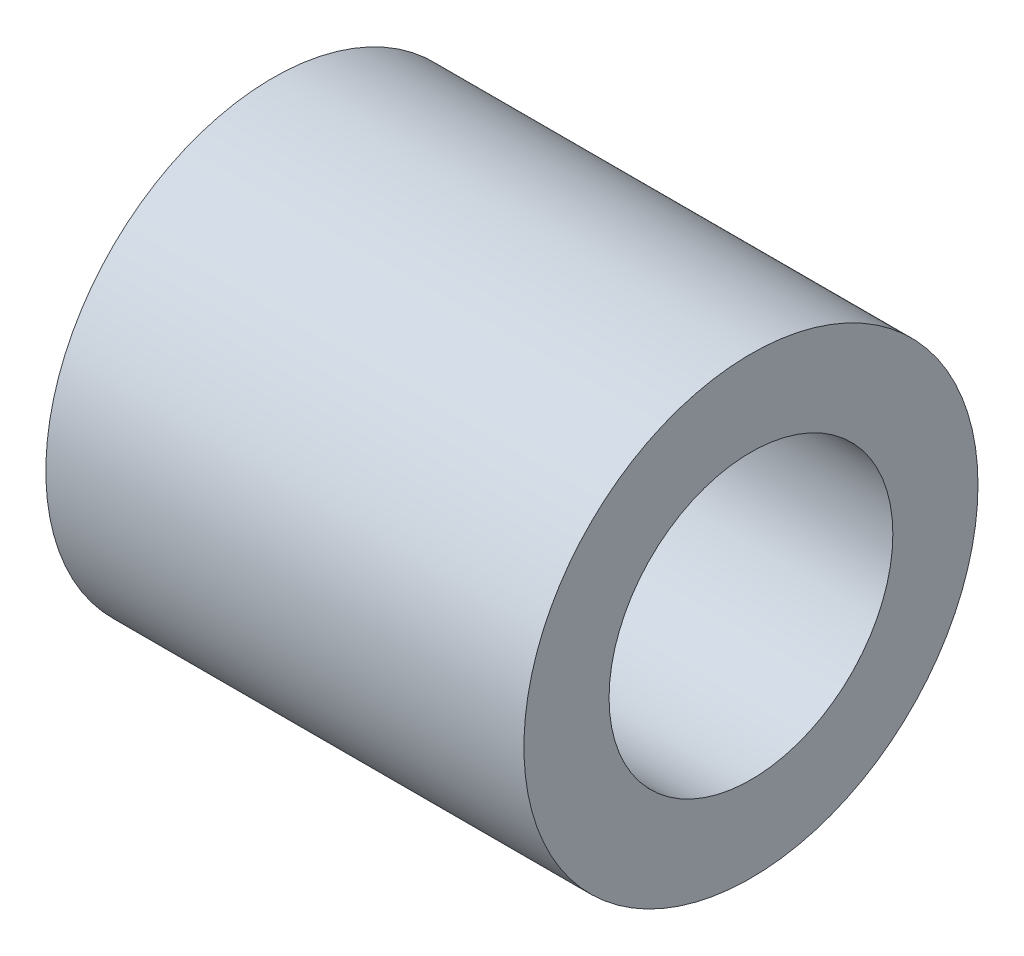
from build123d import *

# Parameters (mm, degrees)
SKETCH1_R           = 4
BOSS_EXTRUDE1_DEPTH = 9
CHAMFER1_SIZE       = 1
CHAMFER1_SIZE2      = 0.577350269
SKETCH2_R           = 2.5
CUT_EXTRUDE1_DEPTH  = 6


with BuildPart() as part:
    # Sketch1 → Boss-Extrude1 (new body)
    with BuildSketch(Plane(origin=(0, 0, 0), x_dir=(0, 0, -1), z_dir=(1, 0, 0))):
        Circle(SKETCH1_R)
    extrude(amount=BOSS_EXTRUDE1_DEPTH)

    # Chamfer1
    chamfer1_edges = [part.edges().sort_by_distance(p)[0] for p in [
        (0, 0, 4),
    ]]
    chamfer1_side = [part.faces().sort_by_distance(p)[0] for p in [
        (0, 0, 0),
    ]]
    chamfer(chamfer1_edges, length=CHAMFER1_SIZE, length2=CHAMFER1_SIZE2, reference=chamfer1_side[0])

    # Sketch2 → Cut-Extrude1 (cut)
    with BuildSketch(Plane(origin=(9, 0, 0), x_dir=(0, 0, -1), z_dir=(1, 0, 0))):
        Circle(SKETCH2_R)
    extrude(amount=-CUT_EXTRUDE1_DEPTH, mode=Mode.SUBTRACT)


solid = part.part
